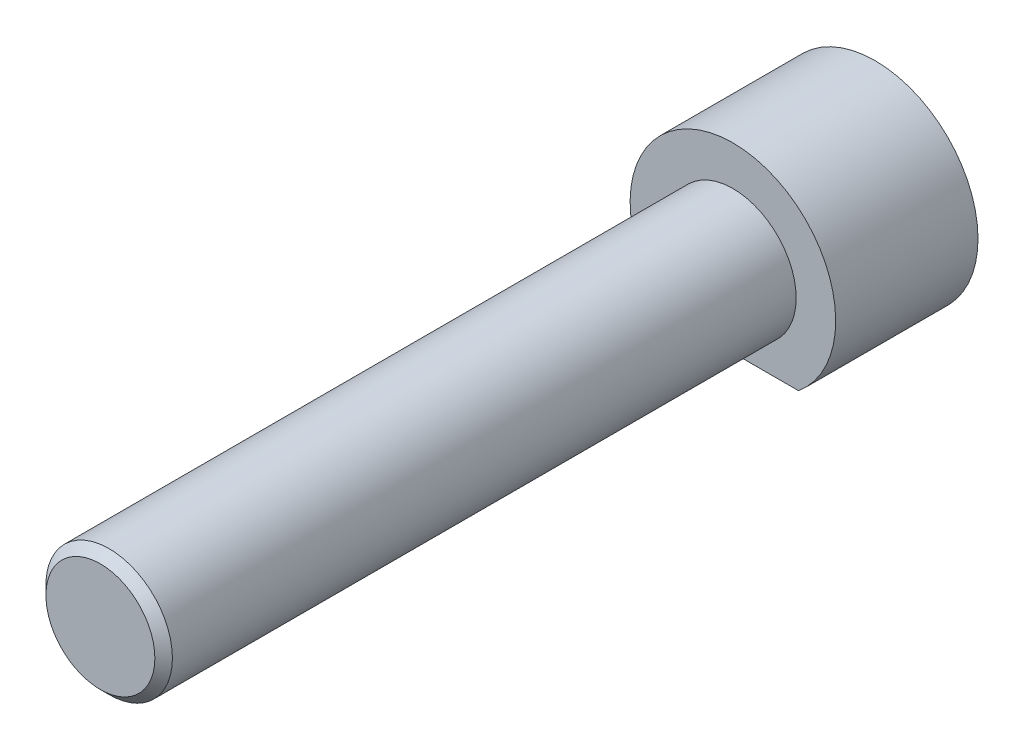
from build123d import *

# Parameters (mm, degrees)
EXTRUDE_1_DEPTH = 9
SKETCH_2_R      = 4
EXTRUDE_2_DEPTH = 40
CHAMFER_1_SIZE  = 0.5545


with BuildPart() as part:
    # Эскиз1 → Бобышка-Вытянуть1 (new body)
    with BuildSketch(Plane.XY):
        with BuildLine():
            ThreePointArc((6.5, 0), (-2.761654617, 5.884153616), (-4.153311931, -5))
            Line((-4.153311931, -5), (4.153311931, -5))
            ThreePointArc((4.153311931, -5), (5.884153616, -2.761654617), (6.5, 0))
        make_face()
    extrude(amount=EXTRUDE_1_DEPTH)

    # Эскиз2 → Бобышка-Вытянуть2 (add)
    with BuildSketch(Plane.XY.offset(9)):
        Circle(SKETCH_2_R)
    extrude(amount=EXTRUDE_2_DEPTH)

    # Фаска1
    chamfer_1_edges = [part.edges().sort_by_distance(p)[0] for p in [
        (-4, 0, 49),
    ]]
    chamfer(chamfer_1_edges, length=CHAMFER_1_SIZE)


solid = part.part
